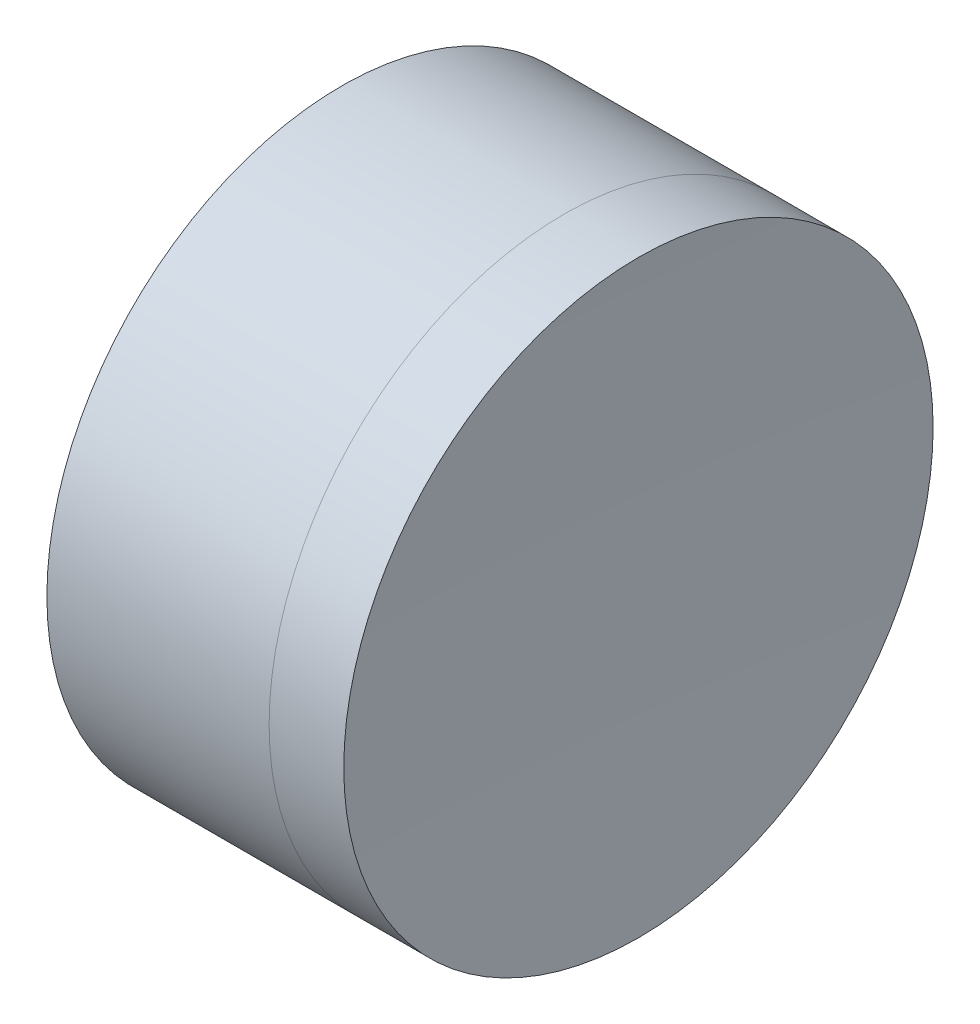
from build123d import *


with BuildPart() as part:
    # 草图1 one side → 旋转1 (revolve)
    with BuildSketch(Plane(origin=(0, 0, 0), x_dir=(1, 0, 0), z_dir=(0, 1, 0)), mode=Mode.PRIVATE) as revolve_1_sk:
        with BuildLine():
            Line((165.406095044, 6.35), (160.617285287, 6.35))
            ThreePointArc((160.617285287, 6.35), (161.933481377, 3.295484147), (162.383174029, 0))
            Line((162.383174029, 0), (163.883174029, 0))
            ThreePointArc((163.883174029, 0), (164.26922703, 3.265034013), (165.406095044, 6.35))
        make_face()
    revolve(revolve_1_sk.sketch.rotate(Axis((-185.274474051, 0, 0), (1, 0, 0)), 180), axis=Axis((-185.274474051, 0, 0), (1, 0, 0)))  # turned: the seam where the file's is


with BuildPart() as body_2:
    # 草图2 one side → 旋转3 (revolve)
    with BuildSketch(Plane(origin=(0, 0, 0), x_dir=(1, 0, 0), z_dir=(0, 1, 0)), mode=Mode.PRIVATE) as revolve_3_sk:
        with BuildLine():
            Line((167.0151764, 6.35), (165.406095044, 6.35))
            ThreePointArc((165.406095044, 6.35), (164.26922703, 3.265034013), (163.883174029, 0))
            Line((163.883174029, 0), (166.883174029, 0))
            ThreePointArc((166.883174029, 0), (166.916178186, 3.175685935), (167.0151764, 6.35))
        make_face()
    revolve(revolve_3_sk.sketch.rotate(Axis((160.617285287, 0, 0), (1, 0, 0)), 180), axis=Axis((160.617285287, 0, 0), (1, 0, 0)))  # turned: the seam where the file's is


solid = Compound([part.part, body_2.part])
